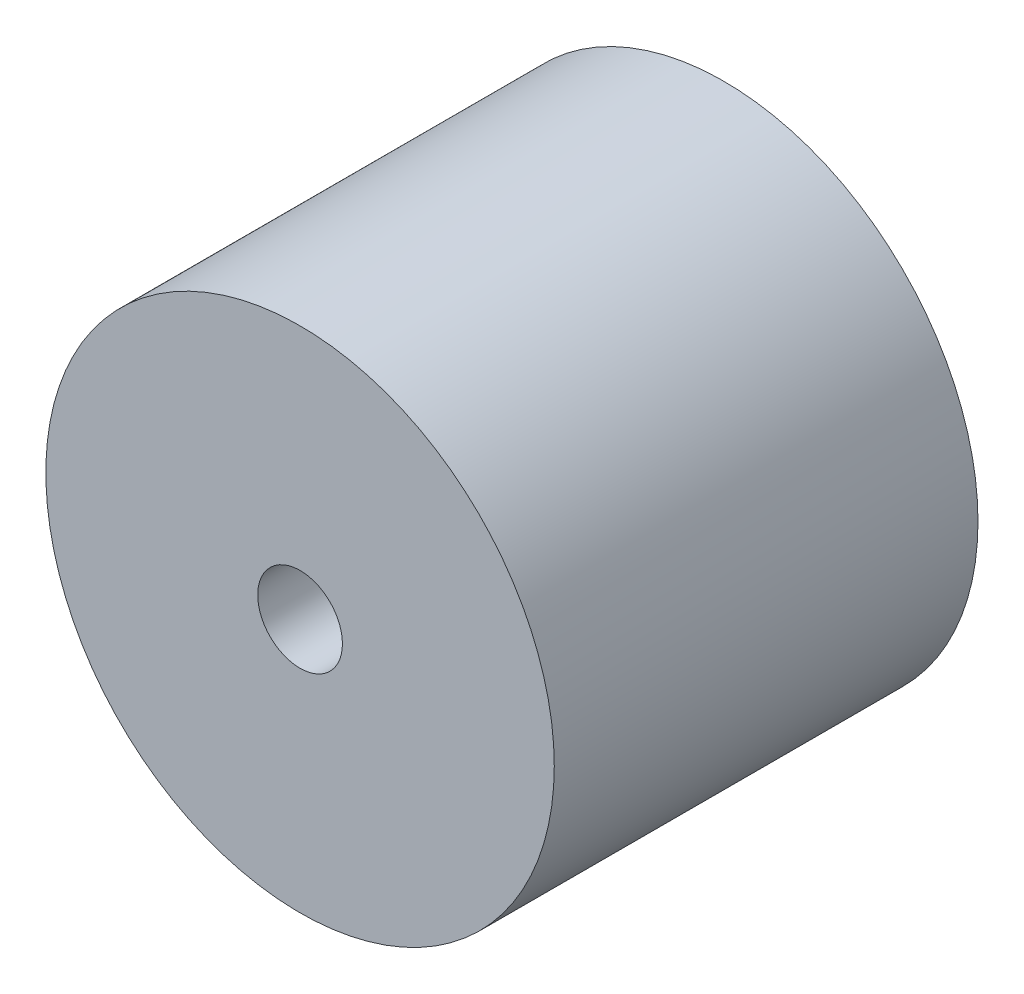
from build123d import *

# Parameters (mm, degrees)
SKETCH1_R           = 18
SKETCH1_R_2         = 3
BOSS_EXTRUDE1_DEPTH = 30


with BuildPart() as part:
    # Sketch1 → Boss-Extrude1 (new body)
    with BuildSketch(Plane.XY):
        Circle(SKETCH1_R)
        Circle(SKETCH1_R_2, mode=Mode.SUBTRACT)
    extrude(amount=BOSS_EXTRUDE1_DEPTH)


solid = part.part
